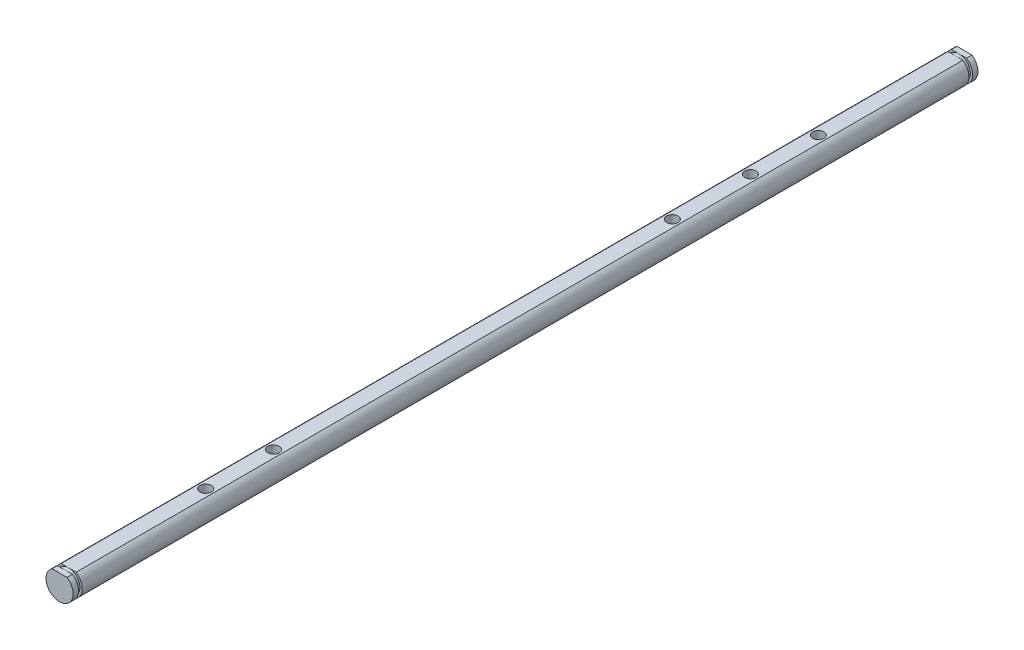
from build123d import *

# Parameters (mm, degrees)
SKETCH1_R           = 3
BOSS_EXTRUDE1_DEPTH = 200
CUT_EXTRUDE1_DEPTH  = 201
M3_TAPPED_HOLE1_D   = 2.5
M3_TAPPED_HOLE2_D   = 2.5
CUT_EXTRUDE2_START  = -1.2
SKETCH9_R           = 3
SKETCH9_R_2         = 2.5
CUT_EXTRUDE2_DEPTH  = 0.8


with BuildPart() as part:
    # Sketch1 → Boss-Extrude1 (new body)
    with BuildSketch(Plane.XY):
        Circle(SKETCH1_R)
    extrude(amount=BOSS_EXTRUDE1_DEPTH)

    # Sketch2 → Cut-Extrude1 (cut, through all)
    with BuildSketch(Plane.XY.offset(200)):
        with BuildLine():
            Line((-1.658312395, 2.5), (1.658312395, 2.5))
            ThreePointArc((1.658312395, 2.5), (0, 3), (-1.658312395, 2.5))
        make_face()
    extrude(amount=-CUT_EXTRUDE1_DEPTH, mode=Mode.SUBTRACT)

    # M3 Tapped Hole1 (through all)
    with Locations(Plane(origin=(0, 2.5, 167.7), x_dir=(0, 0, 1), z_dir=(0, 1, 0))):
        with Locations((0, 0), (-15, 0), (-120.4, 0), (-135.4, 0)):
            Hole(M3_TAPPED_HOLE1_D / 2)

    # M3 Tapped Hole2 (through all)
    with Locations(Plane(origin=(0, 2.5, 64.548836503), x_dir=(0, 0, 1), z_dir=(0, 1, 0))):
        with Locations((0, 0)):
            Hole(M3_TAPPED_HOLE2_D / 2)

    # Sketch9 → Cut-Extrude2 (cut)
    with BuildSketch(Plane.XY.offset(200).offset(CUT_EXTRUDE2_START)):
        Circle(SKETCH9_R)
        Circle(SKETCH9_R_2, mode=Mode.SUBTRACT)
    cut_extrude2 = extrude(amount=-CUT_EXTRUDE2_DEPTH, mode=Mode.SUBTRACT)

    # Mirror1: Cut-Extrude2 across plane
    add(cut_extrude2.mirror(Plane.XY.offset(100)), mode=Mode.SUBTRACT)


solid = part.part
